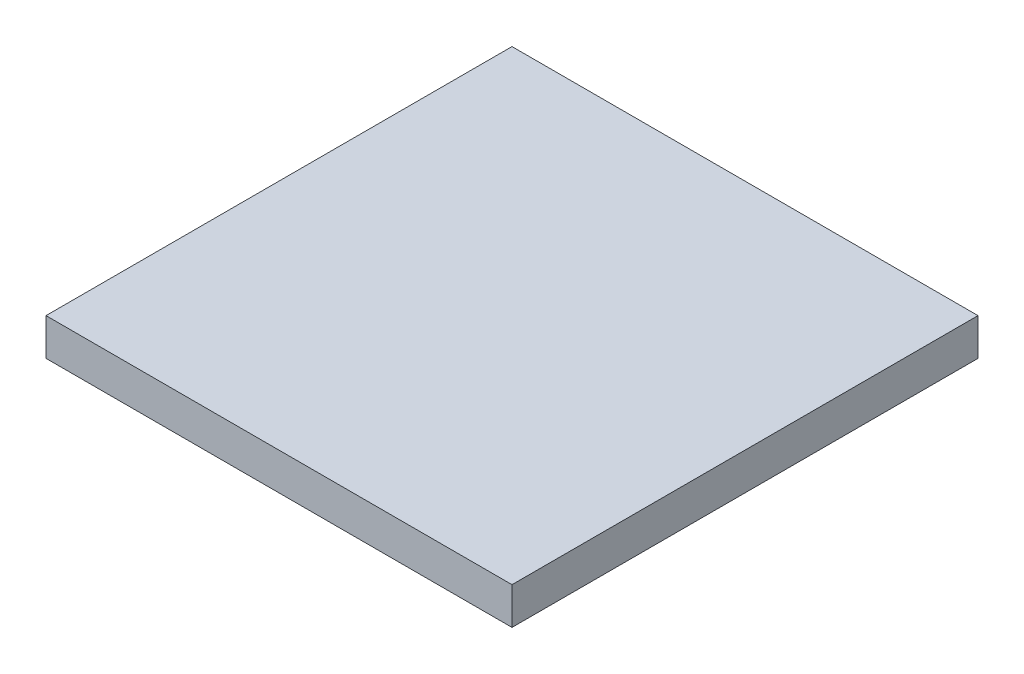
from build123d import *

# Parameters (mm, degrees)
SKETCH3_W           = 20
SKETCH3_H           = 20
BOSS_EXTRUDE1_DEPTH = 1.59


with BuildPart() as part:
    # Sketch3 → Boss-Extrude1 (new body)
    with BuildSketch(Plane(origin=(0, 0, 0), x_dir=(1, 0, 0), z_dir=(0, 1, 0))):
        with Locations((10, 10)):
            Rectangle(SKETCH3_W, SKETCH3_H)
    extrude(amount=BOSS_EXTRUDE1_DEPTH)


solid = part.part
